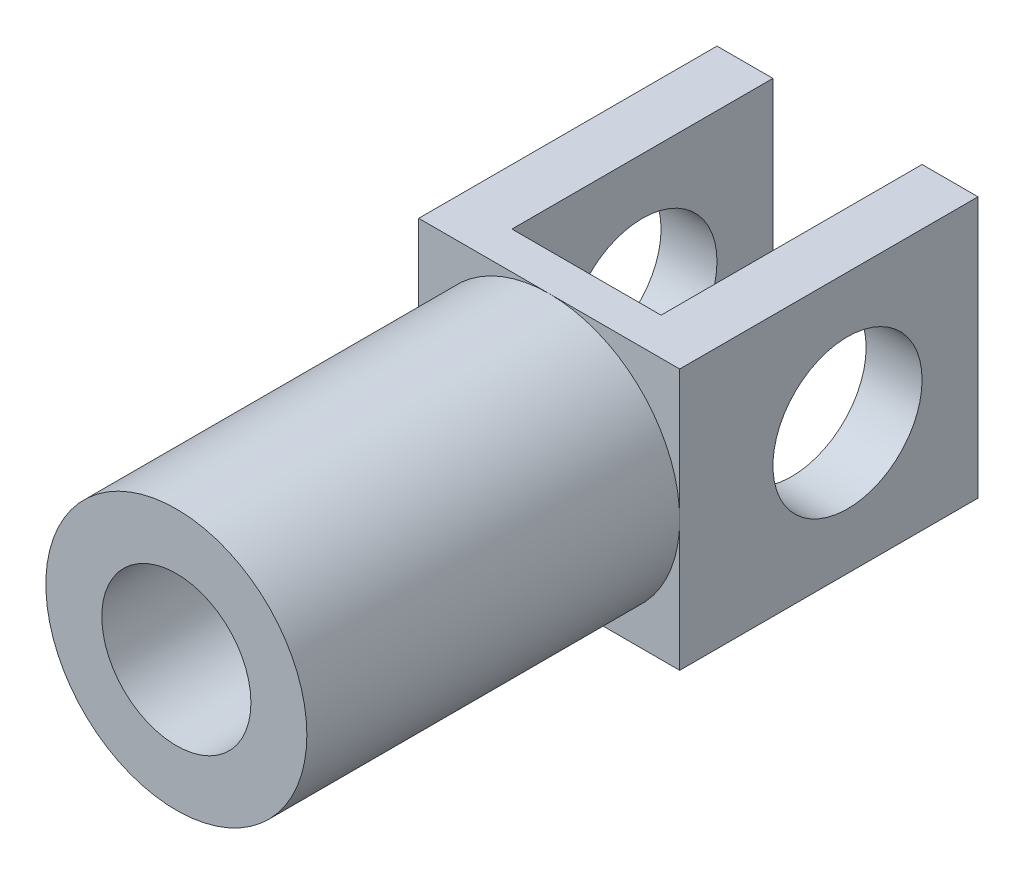
from build123d import *

# Parameters (mm, degrees)
SKETCH1_R               = 3.5
SKETCH1_R_2             = 2
BOSS_EXTRUDE1_DEPTH     = 10
SKETCH2_W               = 7
SKETCH2_H               = 7
BOSS_EXTRUDE2_DEPTH     = 8
SKETCH3_W               = 4
SKETCH3_H               = 10
CUT_EXTRUDE1_DEPTH      = 4.5
CUT_EXTRUDE1_DEPTH_BACK = 4.5
SKETCH4_R               = 2
CUT_EXTRUDE2_DEPTH      = 4.5
CUT_EXTRUDE2_DEPTH_BACK = 4.5


with BuildPart() as part:
    # Sketch1 → Boss-Extrude1 (new body)
    with BuildSketch(Plane.XY):
        Circle(SKETCH1_R)
        Circle(SKETCH1_R_2, mode=Mode.SUBTRACT)
    extrude(amount=BOSS_EXTRUDE1_DEPTH)

    # Sketch2 → Boss-Extrude2 (add)
    with BuildSketch(Plane.XY):
        Rectangle(SKETCH2_W, SKETCH2_H)
    extrude(amount=-BOSS_EXTRUDE2_DEPTH)

    # Sketch3 → Cut-Extrude1 (cut, two sides)
    with BuildSketch(Plane(origin=(0, 0, 0), x_dir=(1, 0, 0), z_dir=(0, 1, 0))) as cut_extrude1_sk:
        with Locations((0, 6)):
            Rectangle(SKETCH3_W, SKETCH3_H)
    extrude(amount=CUT_EXTRUDE1_DEPTH, mode=Mode.SUBTRACT)
    extrude(cut_extrude1_sk.sketch, amount=-CUT_EXTRUDE1_DEPTH_BACK, mode=Mode.SUBTRACT)

    # Sketch4 → Cut-Extrude2 (cut, two sides)
    with BuildSketch(Plane(origin=(0, 0, 0), x_dir=(0, 0, -1), z_dir=(1, 0, 0))) as cut_extrude2_sk:
        with Locations((4.5, 0)):
            Circle(SKETCH4_R)
    extrude(amount=CUT_EXTRUDE2_DEPTH, mode=Mode.SUBTRACT)
    extrude(cut_extrude2_sk.sketch, amount=-CUT_EXTRUDE2_DEPTH_BACK, mode=Mode.SUBTRACT)


solid = part.part
